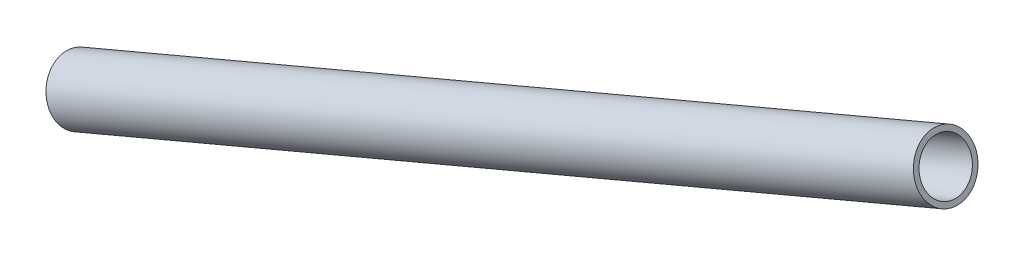
from build123d import *


with BuildPart() as part:
    # Sketch1 → Revolve1 (revolve)
    with BuildSketch(Plane.XY):
        Polygon((-232.754603352, -1448.827609196), (-232.111280558, -1450.348114633), (-506.617419002, -1566.491109936), (-507.260741796, -1564.970604499), align=None)
    revolve(axis=Axis((-235.822758213, -1441.575967882, 0), (-0.920960289, -0.389656447, 0)))


solid = part.part
